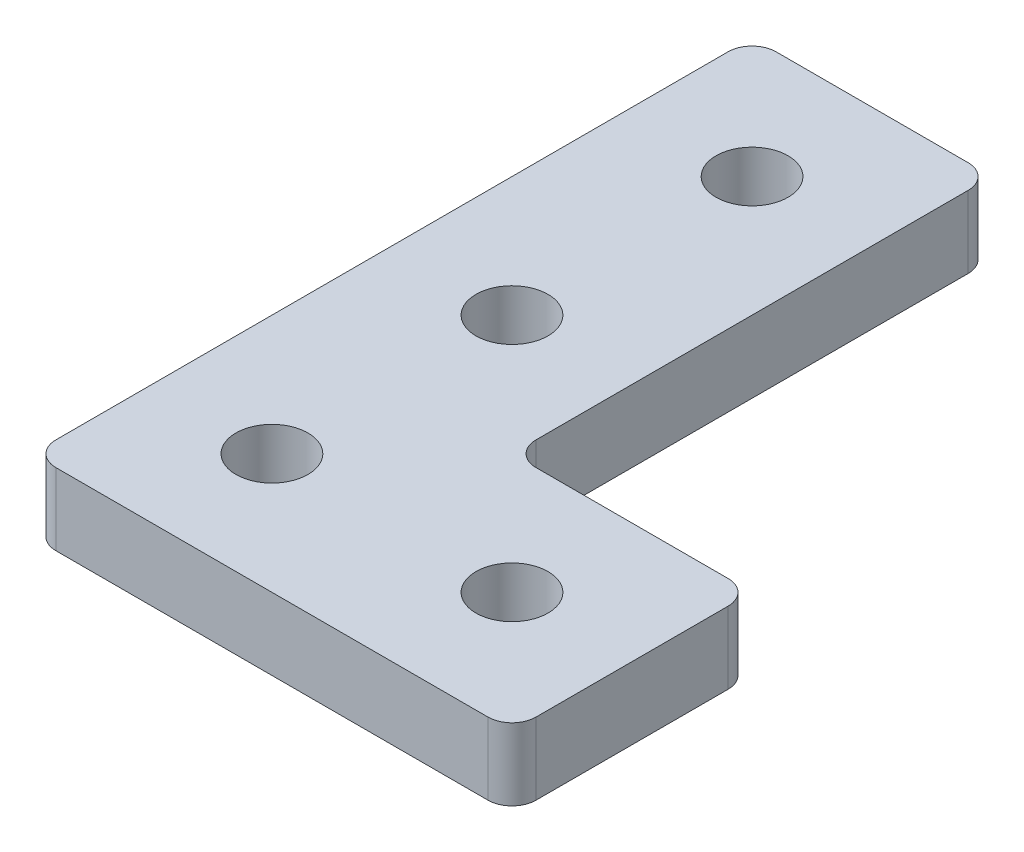
from build123d import *

# Parameters (mm, degrees)
SKETCH1_R           = 1.5
BOSS_EXTRUDE1_DEPTH = 3
FILLET1_R           = 1
FILLET2_R           = 1


with BuildPart() as part:
    # Sketch1 → Boss-Extrude1 (new body)
    with BuildSketch(Plane(origin=(0, 0, 0), x_dir=(1, 0, 0), z_dir=(0, 1, 0))):
        Polygon((0, 0), (10, 0), (20, 0), (20, 10), (10, 10), (10, 30), (0, 30), align=None)
        with Locations((5, 25)):
            Circle(SKETCH1_R, mode=Mode.SUBTRACT)
        with Locations((5, 15)):
            Circle(SKETCH1_R, mode=Mode.SUBTRACT)
        with Locations((5, 5)):
            Circle(SKETCH1_R, mode=Mode.SUBTRACT)
        with Locations((15, 5)):
            Circle(SKETCH1_R, mode=Mode.SUBTRACT)
    extrude(amount=BOSS_EXTRUDE1_DEPTH)

    # Fillet1
    fillet1_edges = [part.edges().sort_by_distance(p)[0] for p in [
        (10, 1.5, -10),
    ]]
    fillet(fillet1_edges, radius=FILLET1_R)

    # Fillet2
    fillet2_edges = [part.edges().sort_by_distance(p)[0] for p in [
        (0, 1.5, -30),
        (10, 1.5, -30),
        (20, 1.5, -10),
        (20, 1.5, 0),
        (0, 1.5, 0),
    ]]
    fillet(fillet2_edges, radius=FILLET2_R)


solid = part.part
